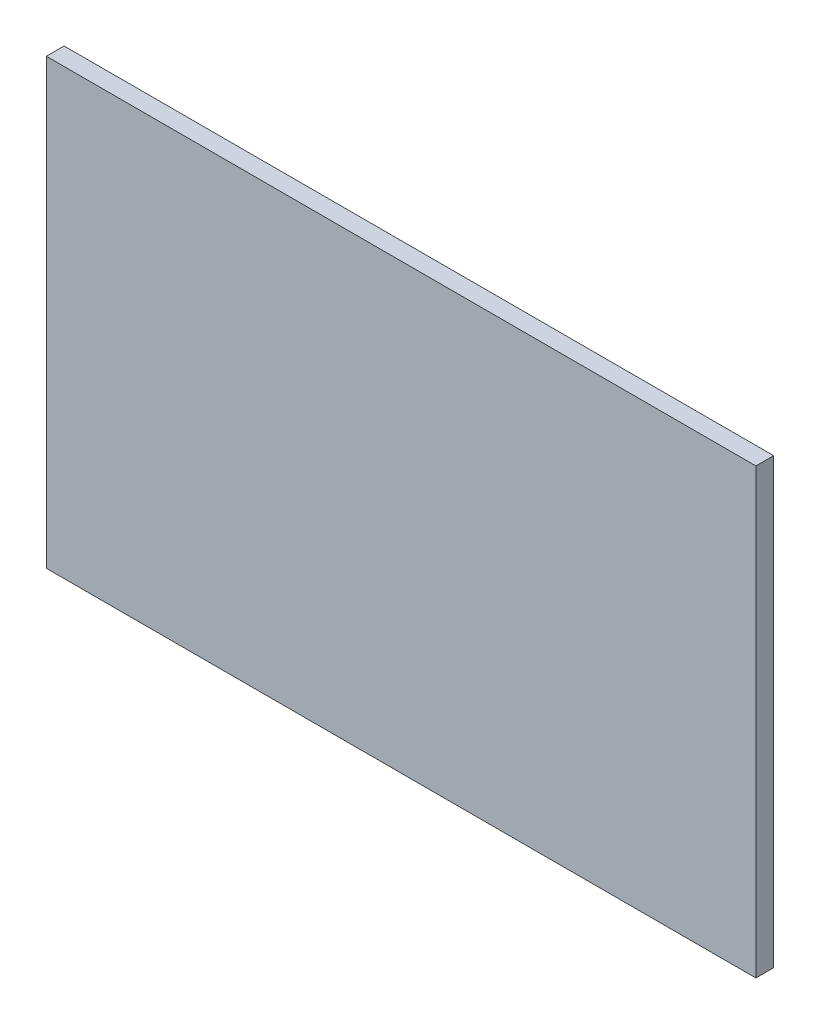
from build123d import *

# Parameters (mm, degrees)
SKETCH1_W           = 400
SKETCH1_H           = 250
BOSS_EXTRUDE1_DEPTH = 10


with BuildPart() as part:
    # Sketch1 → Boss-Extrude1 (new body)
    with BuildSketch(Plane.XY):
        with Locations((200, 125)):
            Rectangle(SKETCH1_W, SKETCH1_H)
    extrude(amount=BOSS_EXTRUDE1_DEPTH)


solid = part.part
